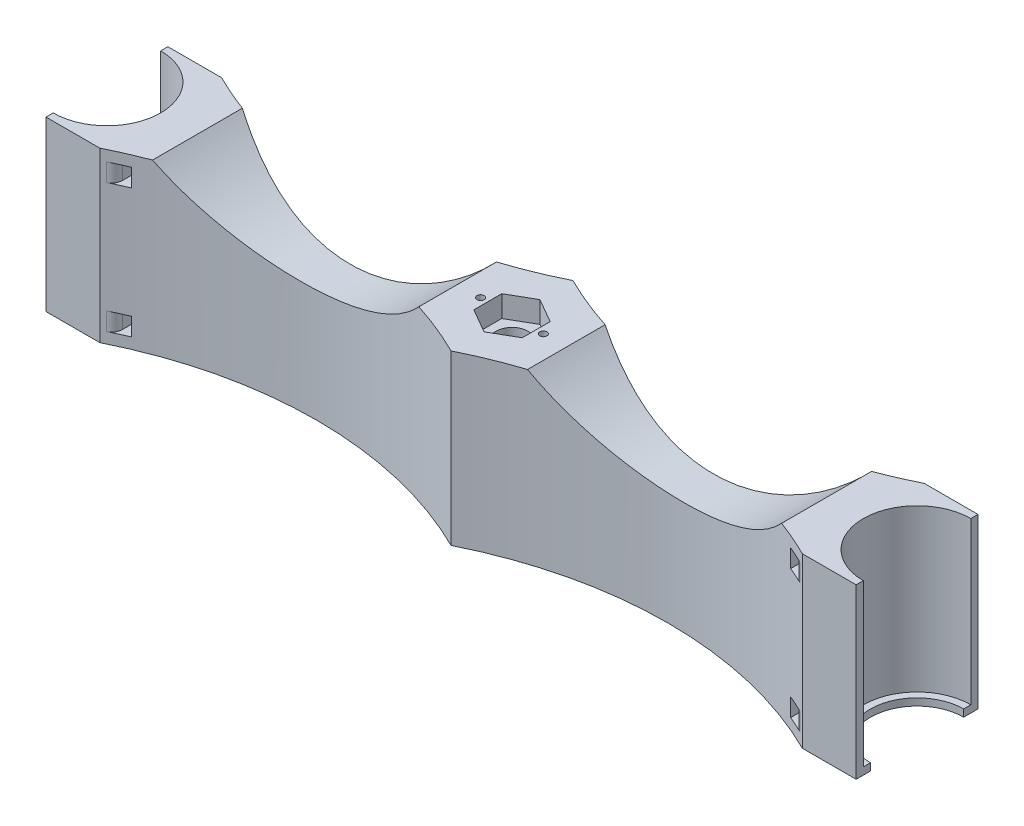
from build123d import *

# Parameters (mm, degrees)
BOSS_EXTRUDE2_DEPTH = 47
SKETCH2_R           = 4.5
CUT_EXTRUDE1_DEPTH  = 48
CUT_EXTRUDE2_DEPTH  = 6
SKETCH4_R           = 1
CUT_EXTRUDE3_DEPTH  = 6
CUT_EXTRUDE4_DEPTH  = 35
CUT_EXTRUDE5_DEPTH  = 6
BOSS_EXTRUDE3_DEPTH = 0.2
BOSS_EXTRUDE4_DEPTH = 2
SKETCH11_W          = 3.045387933
SKETCH11_H          = 5
CUT_EXTRUDE6_DEPTH  = 35.0000001
FILLET1_R           = 3
FILLET2_R           = 3


with BuildPart() as part:
    # Sketch1 → Boss-Extrude2 (new body)
    with BuildSketch(Plane(origin=(0, 0, 0), x_dir=(1, 0, 0), z_dir=(0, 1, 0))):
        with BuildLine():
            Line((0, 15), (0, 17))
            Line((0, 17), (15, 17))
            ThreePointArc((15, 17), (64, 5.483501156), (113, 17))
            ThreePointArc((113, 17), (162, 5.483501156), (211, 17))
            Line((211, 17), (226, 17))
            Line((226, 17), (226, 15))
            ThreePointArc((226, 15), (211, 0), (226, -15))
            Line((226, -15), (226, -17))
            Line((226, -17), (211, -17))
            ThreePointArc((211, -17), (162, -5.483501156), (113, -17))
            ThreePointArc((113, -17), (64, -5.483501156), (15, -17))
            Line((15, -17), (0, -17))
            Line((0, -17), (0, -15))
            ThreePointArc((0, -15), (15, 0), (0, 15))
        make_face()
    extrude(amount=BOSS_EXTRUDE2_DEPTH)

    # Sketch2 → Cut-Extrude1 (cut, through all)
    with BuildSketch(Plane(origin=(0, 47, 0), x_dir=(1, 0, 0), z_dir=(0, 1, 0))):
        with Locations((113, 0)):
            Circle(SKETCH2_R)
    extrude(amount=-CUT_EXTRUDE1_DEPTH, mode=Mode.SUBTRACT)

    # Sketch3 → Cut-Extrude2 (cut)
    with BuildSketch(Plane(origin=(0, 47, 0), x_dir=(1, 0, 0), z_dir=(0, 1, 0))):
        Polygon((113, -7.794228634), (119.75, -3.897114317), (119.75, 3.897114317), (113, 7.794228634), (106.25, 3.897114317), (106.25, -3.897114317), align=None)
    extrude(amount=-CUT_EXTRUDE2_DEPTH, mode=Mode.SUBTRACT)

    # Sketch4 → Cut-Extrude3 (cut)
    with BuildSketch(Plane(origin=(0, 47, 0), x_dir=(1, 0, 0), z_dir=(0, 1, 0))):
        with Locations((104.25, 0)):
            Circle(SKETCH4_R)
        with Locations((121.75, 0)):
            Circle(SKETCH4_R)
    extrude(amount=-CUT_EXTRUDE3_DEPTH, mode=Mode.SUBTRACT)

    # Sketch5 → Cut-Extrude4 (cut, through all)
    with BuildSketch(Plane(origin=(0, 0, -17), x_dir=(-1, 0, 0), z_dir=(0, 0, -1))):
        with BuildLine():
            Line((-200.749560542, 47), (-128.153486501, 47))
            ThreePointArc((-128.153486501, 47), (-164.451523522, 31.359045891), (-200.749560542, 47))
        make_face()
        with BuildLine():
            ThreePointArc((-25.250439458, 47), (-61.548476478, 31.359045891), (-97.846513499, 47))
            Line((-97.846513499, 47), (-25.250439458, 47))
        make_face()
    extrude(amount=-CUT_EXTRUDE4_DEPTH, mode=Mode.SUBTRACT)

    # Sketch6 → Cut-Extrude5 (cut)
    with BuildSketch(Plane.XZ):
        Polygon((120.505553499, 0), (116.75277675, 6.5), (109.24722325, 6.5), (105.494446501, 0), (109.24722325, -6.5), (116.75277675, -6.5), align=None)
    extrude(amount=-CUT_EXTRUDE5_DEPTH, mode=Mode.SUBTRACT)

    # Sketch7 → Boss-Extrude3 (add)
    with BuildSketch(Plane.XZ.offset(-6)):
        Polygon((120.505553499, 0), (116.75277675, 6.5), (109.24722325, 6.5), (105.494446501, 0), (109.24722325, -6.5), (116.75277675, -6.5), align=None)
    extrude(amount=BOSS_EXTRUDE3_DEPTH)

    # Sketch10 → Boss-Extrude4 (add)
    with BuildSketch(Plane.XZ):
        with BuildLine():
            ThreePointArc((226, -13), (213, 0), (226, 13))
            Line((226, 13), (226, 15))
            ThreePointArc((226, 15), (211, 0), (226, -15))
            Line((226, -15), (226, -13))
        make_face()
    extrude(amount=-BOSS_EXTRUDE4_DEPTH)

    # Sketch11 → Cut-Extrude6 (cut, through all)
    with BuildSketch(Plane(origin=(0, 0, -17), x_dir=(-1, 0, 0), z_dir=(0, 0, -1))):
        with Locations((-19.522693967, 41.5)):
            Rectangle(SKETCH11_W, SKETCH11_H)
        with Locations((-19.522693967, 5.5)):
            Rectangle(SKETCH11_W, SKETCH11_H)
        with Locations((-206.477306033, 5.5)):
            Rectangle(SKETCH11_W, SKETCH11_H)
        with Locations((-206.477306033, 41.5)):
            Rectangle(SKETCH11_W, SKETCH11_H)
    extrude(amount=-CUT_EXTRUDE6_DEPTH, mode=Mode.SUBTRACT)

    # Fillet1
    fillet1_edges = [part.edges().sort_by_distance(p)[0] for p in [
        (18, 41.5, -15.563533182),
        (18, 5.5, -15.563533182),
    ]]
    fillet(fillet1_edges, radius=FILLET1_R)

    # Fillet2
    fillet2_edges = [part.edges().sort_by_distance(p)[0] for p in [
        (18, 41.5, 15.563533182),
        (18, 5.5, 15.563533182),
        (208, 5.5, -15.563533182),
        (208, 5.5, 15.563533182),
        (208, 41.5, -15.563533182),
        (208, 41.5, 15.563533182),
    ]]
    fillet(fillet2_edges, radius=FILLET2_R)


solid = part.part
